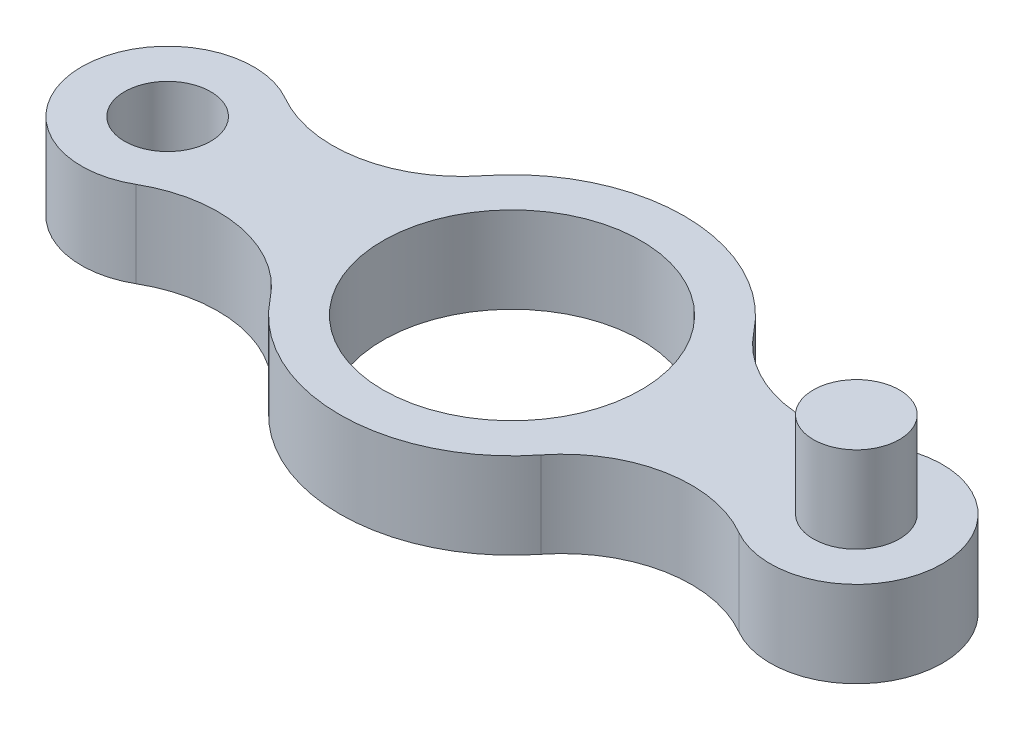
from build123d import *

# Parameters (mm, degrees)
SALIENTE_EXTRUIR1_DEPTH = 20
CROQUIS2_R              = 30
CORTAR_EXTRUIR1_DEPTH   = 21
CROQUIS3_R              = 10
CORTAR_EXTRUIR2_DEPTH   = 21
CROQUIS4_R              = 10
SALIENTE_EXTRUIR2_DEPTH = 20


with BuildPart() as part:
    # Croquis1 → Saliente-Extruir1 (new body)
    with BuildSketch(Plane(origin=(0, 0, 0), x_dir=(1, 0, 0), z_dir=(0, 1, 0))):
        with BuildLine():
            ThreePointArc((70, -17.320508076), (100, 0), (70, 17.320508076))
            ThreePointArc((70, 17.320508076), (49.330532905, 13.841855007), (31.428571429, 24.743582965))
            ThreePointArc((31.428571429, 24.743582965), (0, 40), (-31.428571429, 24.743582965))
            ThreePointArc((-31.428571429, 24.743582965), (-49.330532905, 13.841855007), (-70, 17.320508076))
            ThreePointArc((-70, 17.320508076), (-100, 0), (-70, -17.320508076))
            ThreePointArc((-70, -17.320508076), (-49.330532905, -13.841855007), (-31.428571429, -24.743582965))
            ThreePointArc((-31.428571429, -24.743582965), (0, -40), (31.428571429, -24.743582965))
            ThreePointArc((31.428571429, -24.743582965), (49.330532905, -13.841855007), (70, -17.320508076))
        make_face()
    extrude(amount=SALIENTE_EXTRUIR1_DEPTH)

    # Croquis2 → Cortar-Extruir1 (cut, through all)
    with BuildSketch(Plane(origin=(0, 20, 0), x_dir=(1, 0, 0), z_dir=(0, 1, 0))):
        Circle(CROQUIS2_R)
    extrude(amount=-CORTAR_EXTRUIR1_DEPTH, mode=Mode.SUBTRACT)

    # Croquis3 → Cortar-Extruir2 (cut, through all)
    with BuildSketch(Plane(origin=(0, 20, 0), x_dir=(1, 0, 0), z_dir=(0, 1, 0))):
        with Locations((-80, 0)):
            Circle(CROQUIS3_R)
    extrude(amount=-CORTAR_EXTRUIR2_DEPTH, mode=Mode.SUBTRACT)

    # Croquis4 → Saliente-Extruir2 (add)
    with BuildSketch(Plane(origin=(0, 20, 0), x_dir=(1, 0, 0), z_dir=(0, 1, 0))):
        with Locations((80, 0)):
            Circle(CROQUIS4_R)
    extrude(amount=SALIENTE_EXTRUIR2_DEPTH)


solid = part.part
